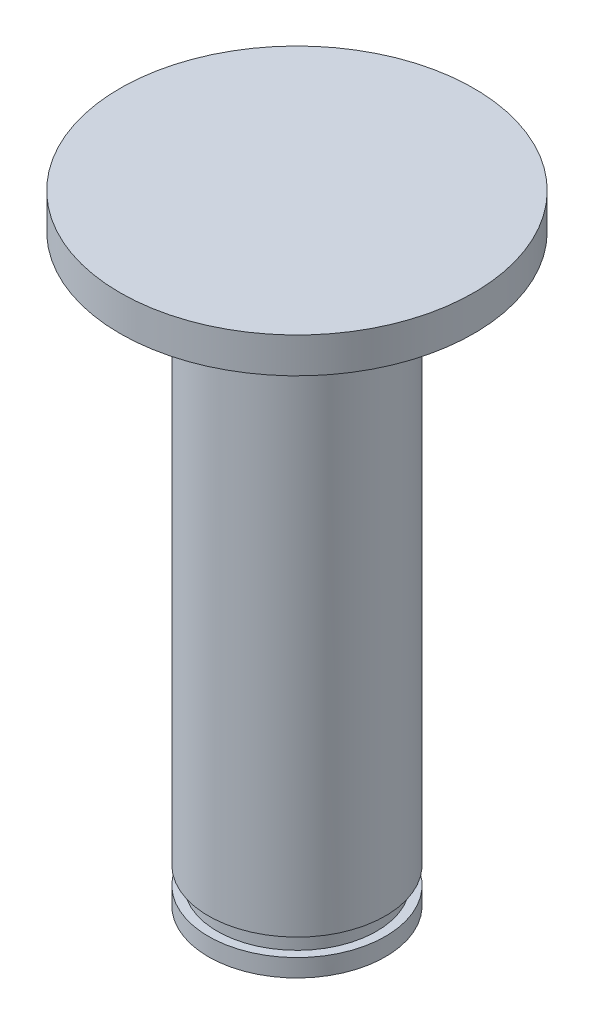
from build123d import *

# Parameters (mm, degrees)
CROQUIS1_R              = 5
SALIENTE_EXTRUIR1_DEPTH = 33
CROQUIS2_R              = 10
SALIENTE_EXTRUIR2_DEPTH = 2
SKETCH3_R               = 5
SKETCH3_R_2             = 4.5
CUT_EXTRUDE1_DEPTH      = 1


with BuildPart() as part:
    # Croquis1 → Saliente-Extruir1 (new body)
    with BuildSketch(Plane(origin=(0, 0, 0), x_dir=(1, 0, 0), z_dir=(0, 1, 0))):
        Circle(CROQUIS1_R)
    extrude(amount=SALIENTE_EXTRUIR1_DEPTH)

    # Croquis2 → Saliente-Extruir2 (add)
    with BuildSketch(Plane(origin=(0, 33, 0), x_dir=(1, 0, 0), z_dir=(0, 1, 0))):
        Circle(CROQUIS2_R)
    extrude(amount=SALIENTE_EXTRUIR2_DEPTH)

    # Sketch3 → Cut-Extrude1 (cut)
    with BuildSketch(Plane(origin=(0, 2, 0), x_dir=(-1, 0, 0), z_dir=(0, -1, 0))):
        Circle(SKETCH3_R)
        Circle(SKETCH3_R_2, mode=Mode.SUBTRACT)
    extrude(amount=CUT_EXTRUDE1_DEPTH, mode=Mode.SUBTRACT)


solid = part.part
